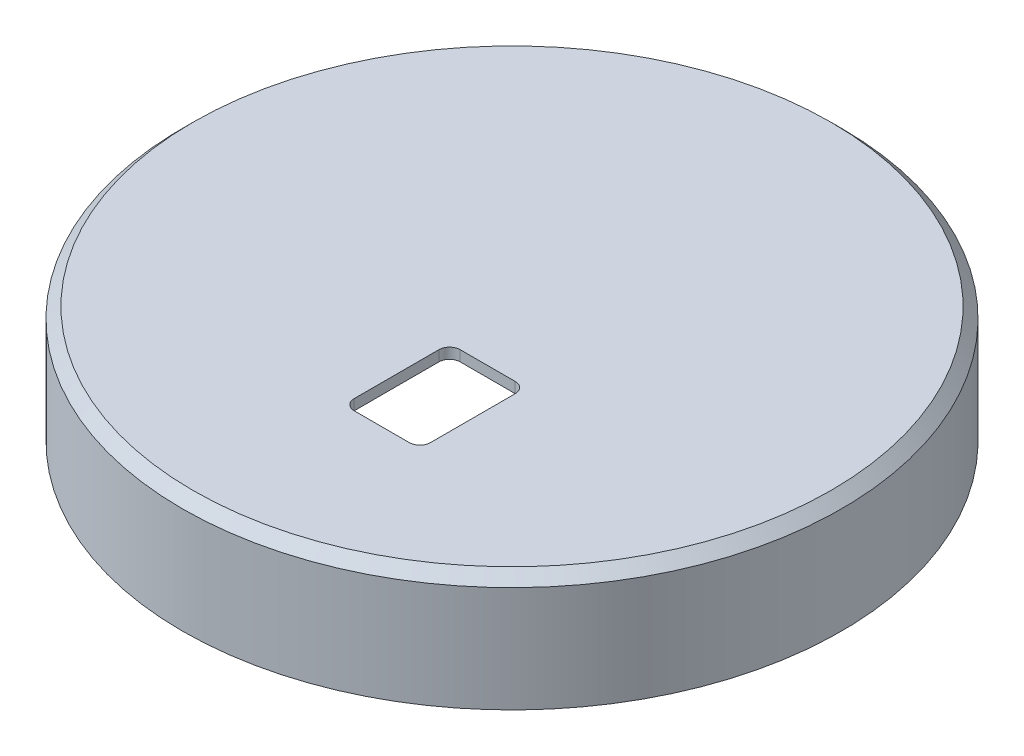
from build123d import *

# Parameters (mm, degrees)
SKIZZE1_R                       = 31.112698372
SKIZZE1_R_2                     = 29.112698372
AUFSATZ_LINEAR_AUSTRAGEN1_DEPTH = 10
SKIZZE2_R                       = 31.112698372
AUFSATZ_LINEAR_AUSTRAGEN2_DEPTH = 1
AUFSATZ_LINEAR_AUSTRAGEN3_DEPTH = 10
SKIZZE5_R                       = 1.425
SCHNITT_LINEAR_AUSTRAGEN2_DEPTH = 10
SKIZZE6_W                       = 7.2
SKIZZE6_H                       = 10
SCHNITT_LINEAR_AUSTRAGEN3_DEPTH = 10
KREISMUSTER1_COUNT              = 2
KREISMUSTER1_ANGLE              = 90
FASE1_SIZE                      = 1
VERRUNDUNG1_R                   = 2
VERRUNDUNG2_R                   = 1
FASE2_SIZE                      = 1


with BuildPart() as part:
    # Skizze1 → Aufsatz-Linear austragen1 (new body)
    with BuildSketch(Plane(origin=(0, 0, 0), x_dir=(1, 0, 0), z_dir=(0, 1, 0))):
        Circle(SKIZZE1_R)
        Circle(SKIZZE1_R_2, mode=Mode.SUBTRACT)
    extrude(amount=AUFSATZ_LINEAR_AUSTRAGEN1_DEPTH)

    # Skizze2 → Aufsatz-Linear austragen2 (add)
    with BuildSketch(Plane(origin=(0, 10, 0), x_dir=(1, 0, 0), z_dir=(0, 1, 0))):
        Circle(SKIZZE2_R)
    extrude(amount=AUFSATZ_LINEAR_AUSTRAGEN2_DEPTH)

    # Skizze4 → Aufsatz-Linear austragen3 (add)
    with BuildSketch(Plane.XZ.offset(-10)):
        with BuildLine():
            ThreePointArc((28.766387333, -4.477071177), (29.112698372, 0), (28.766387333, 4.477071177))
            ThreePointArc((28.766387333, 4.477071177), (23.812698372, 0), (28.766387333, -4.477071177))
        make_face()
        with BuildLine():
            ThreePointArc((-28.766387333, -4.477071177), (-23.812698372, 0), (-28.766387333, 4.477071177))
            ThreePointArc((-28.766387333, 4.477071177), (-29.112698372, 0), (-28.766387333, -4.477071177))
        make_face()
    aufsatz_linear_austragen3 = extrude(amount=AUFSATZ_LINEAR_AUSTRAGEN3_DEPTH)

    # Skizze5 → Schnitt-Linear austragen2 (cut)
    with BuildSketch(Plane.XZ):
        with Locations((-27.712698372, 0)):
            Circle(SKIZZE5_R)
        with BuildLine():
            ThreePointArc((29.137698372, 0), (27.712698372, 1.425), (26.287698372, 0))
            Line((26.287698372, 0), (29.137698372, 0))
        make_face()
        with BuildLine():
            Line((29.137698372, 0), (26.287698372, 0))
            ThreePointArc((26.287698372, 0), (27.712698372, -1.425), (29.137698372, 0))
        make_face()
        with BuildLine():
            ThreePointArc((29.137698372, 0), (27.712698372, 1.425), (26.287698372, 0))
            Line((26.287698372, 0), (29.137698372, 0))
        make_face()
        with BuildLine():
            Line((29.137698372, 0), (26.287698372, 0))
            ThreePointArc((26.287698372, 0), (27.712698372, -1.425), (29.137698372, 0))
        make_face()
    schnitt_linear_austragen2 = extrude(amount=-SCHNITT_LINEAR_AUSTRAGEN2_DEPTH, mode=Mode.SUBTRACT)

    # Skizze6 → Schnitt-Linear austragen3 (cut)
    with BuildSketch(Plane(origin=(0, 11, 0), x_dir=(1, 0, 0), z_dir=(0, 1, 0))):
        with Locations((3.69194255, -10.988)):
            Rectangle(SKIZZE6_W, SKIZZE6_H)
    extrude(amount=-SCHNITT_LINEAR_AUSTRAGEN3_DEPTH, mode=Mode.SUBTRACT)

    # Kreismuster1: Aufsatz-Linear austragen3, Schnitt-Linear austragen2 ×2 about axis
    kreismuster1_axis = Axis((0, 0, 0), (0, 1, 0))
    for i in range(1, KREISMUSTER1_COUNT):
        add(aufsatz_linear_austragen3.rotate(kreismuster1_axis, i * KREISMUSTER1_ANGLE / (KREISMUSTER1_COUNT - 1)))
        add(schnitt_linear_austragen2.rotate(kreismuster1_axis, i * KREISMUSTER1_ANGLE / (KREISMUSTER1_COUNT - 1)), mode=Mode.SUBTRACT)

    # Fase1
    fase1_edges = [part.edges().sort_by_distance(p)[0] for p in [
        (-31.112698372, 11, 0),
    ]]
    chamfer(fase1_edges, length=FASE1_SIZE)

    # Verrundung1
    verrundung1_edges = [part.edges().sort_by_distance(p)[0] for p in [
        (-28.766387333, 5, 4.477071177),
        (-28.766387333, 5, -4.477071177),
        (28.766387333, 5, 4.477071177),
        (28.766387333, 5, -4.477071177),
        (4.477071177, 5, 28.766387333),
        (-4.477071177, 5, 28.766387333),
        (4.477071177, 5, -28.766387333),
        (-4.477071177, 5, -28.766387333),
    ]]
    fillet(verrundung1_edges, radius=VERRUNDUNG1_R)

    # Verrundung2
    verrundung2_edges = [part.edges().sort_by_distance(p)[0] for p in [
        (7.29194255, 10.5, 5.988),
        (7.29194255, 10.5, 15.988),
        (0.09194255, 10.5, 15.988),
        (0.09194255, 10.5, 5.988),
    ]]
    fillet(verrundung2_edges, radius=VERRUNDUNG2_R)

    # Fase2
    fase2_edges = [part.edges().sort_by_distance(p)[0] for p in [
        (-20.585786438, 10, -20.585786438),
        (0, 10, -23.812698372),
        (20.585786438, 10, -20.585786438),
        (23.812698372, 10, 0),
        (20.585786438, 10, 20.585786438),
        (0, 10, 23.812698372),
        (-20.585786438, 10, 20.585786438),
        (-23.812698372, 10, 0),
        (-5.216208543, 10, 28.127764738),
        (5.216208543, 10, 28.127764738),
        (-28.127764738, 10, -5.216208543),
        (-28.127764738, 10, 5.216208543),
        (28.127764738, 10, 5.216208543),
        (28.127764738, 10, -5.216208543),
        (5.216208543, 10, -28.127764738),
        (-5.216208543, 10, -28.127764738),
    ]]
    chamfer(fase2_edges, length=FASE2_SIZE)


solid = part.part
